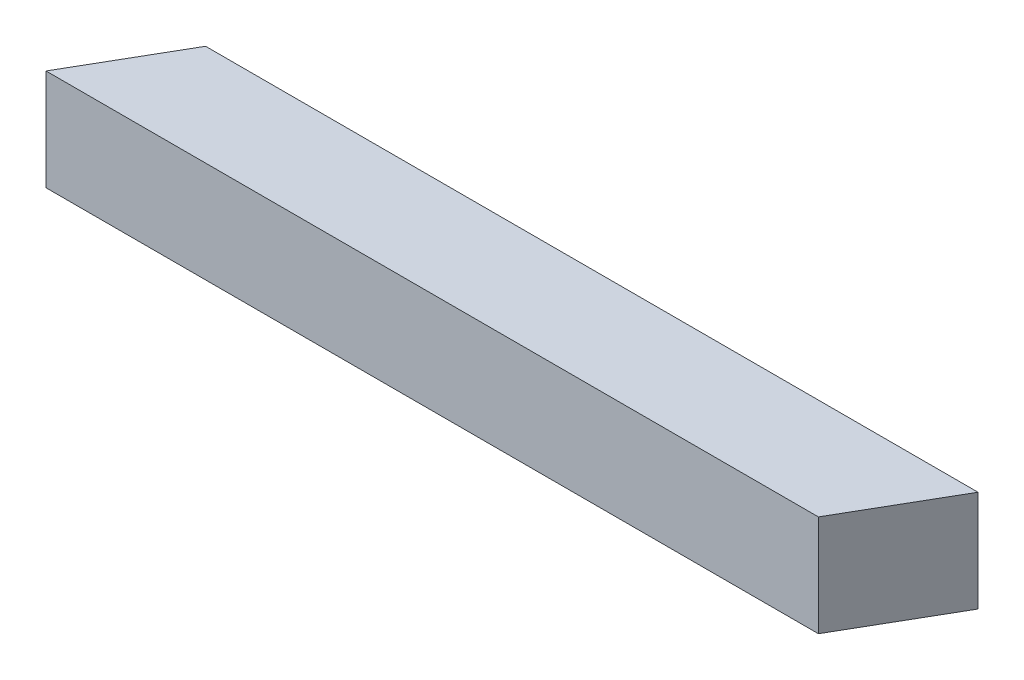
from build123d import *

# Parameters (mm, degrees)
BOSS_EXTRUDE1_DEPTH = 20


with BuildPart() as part:
    # Sketch1 → Boss-Extrude1 (new body)
    with BuildSketch(Plane(origin=(0, 0, 0), x_dir=(1, 0, 0), z_dir=(0, 1, 0))):
        Polygon((70.566497308, -10), (82.113502692, 10), (0, 10), (-70.566497308, 10), (-82.113502692, -10), (0, -10), align=None)
    extrude(amount=BOSS_EXTRUDE1_DEPTH)


solid = part.part
